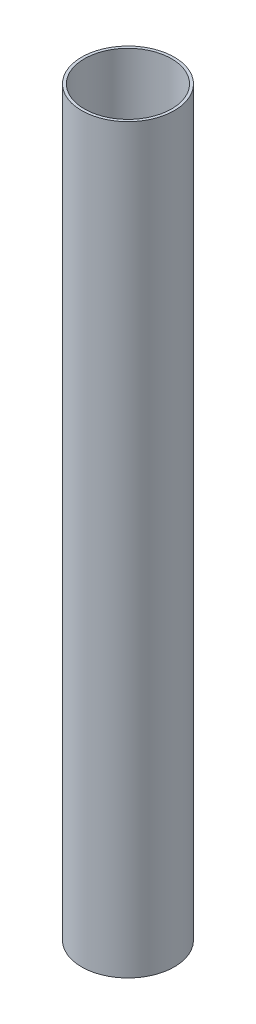
from build123d import *

# Parameters (mm, degrees)
SKETCH1_R   = 6.35
SKETCH1_R_2 = 5.969


with BuildPart() as part:
    # Sweep1: sweep along a path in Sketch2
    with BuildLine(Plane(origin=(0, 0, 0), x_dir=(0, 0, -1), z_dir=(1, 0, 0))) as sweep1_path:
        Line((0, 0), (0, -101.6))
    # Sketch1 → Sweep1 (sweep)
    with BuildSketch(Plane(origin=(0, 0, 0), x_dir=(1, 0, 0), z_dir=(0, 1, 0))):
        Circle(SKETCH1_R)
        Circle(SKETCH1_R_2, mode=Mode.SUBTRACT)
    sweep(path=sweep1_path.line)


solid = part.part
